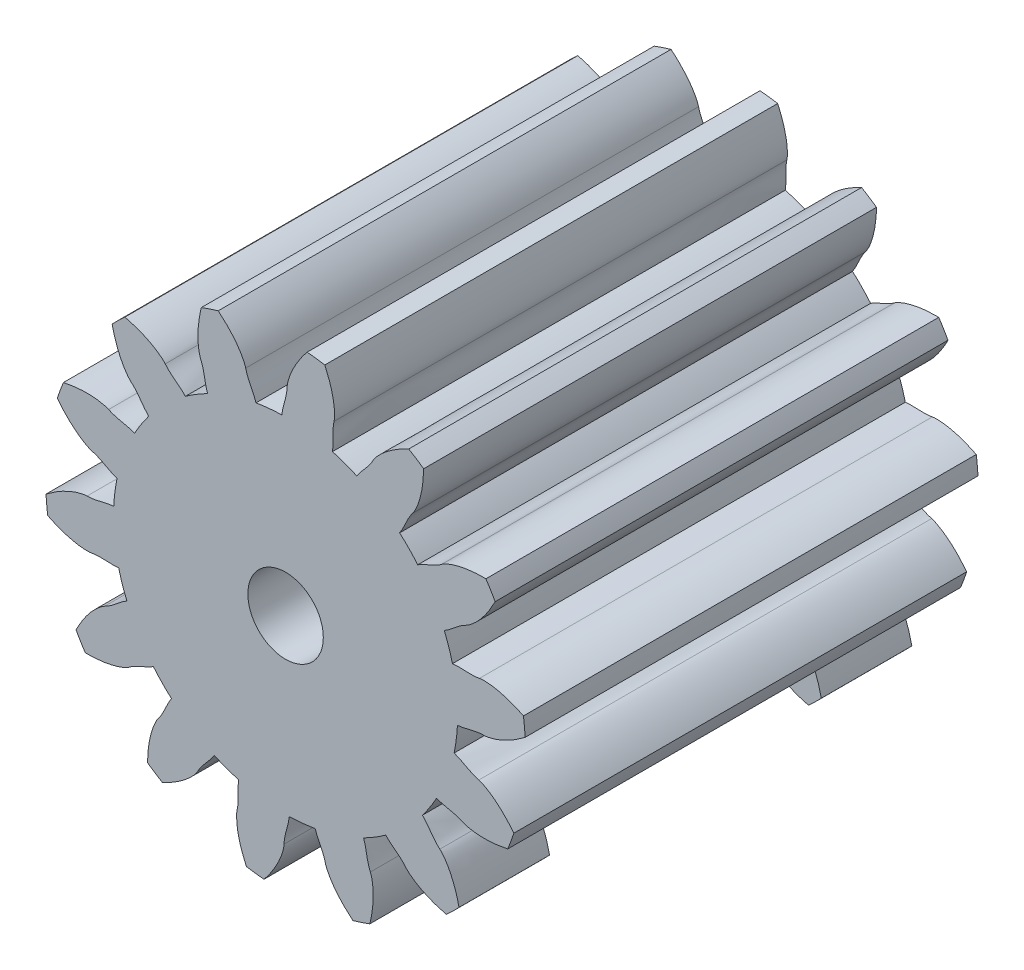
from build123d import *

# Parameters (mm, degrees)
EXTRUDE_1_DEPTH     = 30
SKETCH_4_R          = 2.5
CUT_EXTRUDE_1_DEPTH = 66
CUT_EXTRUDE_START   = -6
CUT_EXTRUDE_2_DEPTH = 18


with BuildPart() as part:
    # 草图3 → 凸台-拉伸1 (new body)
    with BuildSketch(Plane.XY):
        with BuildLine():
            ThreePointArc((-5.16915257, 10.160701832), (-5.920631824, 9.741977151), (-6.638396304, 9.267777215))
            add(Edge.make_bspline(
                [(-6.638396304, 9.267777215), (-6.690388584, 9.321524895), (-6.742285564, 9.375374413), (-6.851473177, 9.477309725), (-6.907912341, 9.526305408), (-7.080462978, 9.66983748), (-7.199376592, 9.760655037), (-7.552933918, 10.037083253), (-7.785800299, 10.227892454), (-7.970905806, 10.463685805)],
                knots=[0, 0, 0, 0, 0.125, 0.125, 0.25, 0.25, 0.5, 0.5, 1, 1, 1, 1], degree=3))
            add(Edge.make_bspline(
                [(-7.970905806, 10.463685805), (-8.010602828, 10.514253148), (-8.056096553, 10.558060329), (-8.148386682, 10.644155499), (-8.196244739, 10.685205378), (-8.343350395, 10.804236571), (-8.446517678, 10.878185133), (-8.764032329, 11.086469421), (-8.985827606, 11.207046594), (-9.67250883, 11.530309395), (-10.152057253, 11.691198834), (-10.643696882, 11.811931116)],
                knots=[0, 0, 0, 0, 0.0625, 0.0625, 0.125, 0.125, 0.25, 0.25, 0.5, 0.5, 1, 1, 1, 1], degree=3))
            ThreePointArc((-10.643696882, 11.811931116), (-11.074186923, 11.409311285), (-11.489458252, 10.991012195))
            add(Edge.make_bspline(
                [(-11.489458252, 10.991012195), (-11.38347984, 10.496213832), (-11.236294102, 10.010267524), (-10.934006793, 9.315376381), (-10.819398101, 9.088979282), (-10.621739867, 8.767211548), (-10.551508259, 8.662694281), (-10.436783614, 8.511828112), (-10.396895617, 8.462380662), (-10.313124681, 8.367024558), (-10.270456441, 8.320097003), (-10.221471948, 8.279225278)],
                knots=[0, 0, 0, 0, 0.5, 0.5, 0.75, 0.75, 0.875, 0.875, 0.9375, 0.9375, 1, 1, 1, 1], degree=3))
            add(Edge.make_bspline(
                [(-10.221471948, 8.279225278), (-9.99128373, 8.08716062), (-9.807518072, 7.848726952), (-9.54175471, 7.487094574), (-9.454526905, 7.365533837), (-9.316196827, 7.188775305), (-9.268899165, 7.130893563), (-9.170260023, 7.018712582), (-9.117982113, 6.96523489), (-9.065808842, 6.911664781)],
                knots=[0, 0, 0, 0, 0.5, 0.5, 0.75, 0.75, 0.875, 0.875, 1, 1, 1, 1], degree=3))
            ThreePointArc((-9.065808842, 6.911664781), (-9.561190424, 6.208352251), (-10.002126234, 5.469686536))
            add(Edge.make_bspline(
                [(-10.002126234, 5.469686536), (-10.072289904, 5.495552917), (-10.142411898, 5.521552401), (-10.285014612, 5.566018213), (-10.357122972, 5.585673763), (-10.574861956, 5.640124775), (-10.721403681, 5.670353884), (-11.159885533, 5.766004326), (-11.452479902, 5.836880539), (-11.721561102, 5.969008738)],
                knots=[0, 0, 0, 0, 0.125, 0.125, 0.25, 0.25, 0.5, 0.5, 1, 1, 1, 1], degree=3))
            add(Edge.make_bspline(
                [(-11.721561102, 5.969008738), (-11.779267231, 5.997344448), (-11.839262885, 6.017074367), (-11.959768712, 6.054600249), (-12.020698207, 6.070820078), (-12.204881522, 6.114236725), (-12.32991711, 6.136099472), (-12.706359092, 6.185992687), (-12.958506206, 6.198395601), (-13.717443083, 6.191705504), (-14.219308595, 6.128593618), (-14.714644369, 6.024055204)],
                knots=[0, 0, 0, 0, 0.0625, 0.0625, 0.125, 0.125, 0.25, 0.25, 0.5, 0.5, 1, 1, 1, 1], degree=3))
            ThreePointArc((-14.714644369, 6.024055204), (-14.927812296, 5.474524642), (-15.120465662, 4.917470708))
            add(Edge.make_bspline(
                [(-15.120465662, 4.917470708), (-14.810297448, 4.517655096), (-14.46684348, 4.1436941), (-13.892990057, 3.648776361), (-13.691501174, 3.494526471), (-13.373807471, 3.290384453), (-13.265182637, 3.226690002), (-13.096360925, 3.140541439), (-13.038968637, 3.113297579), (-12.922120169, 3.063731545), (-12.86331631, 3.039964335), (-12.80144923, 3.024393757)],
                knots=[0, 0, 0, 0, 0.5, 0.5, 0.75, 0.75, 0.875, 0.875, 0.9375, 0.9375, 1, 1, 1, 1], degree=3))
            add(Edge.make_bspline(
                [(-12.80144923, 3.024393757), (-12.51072308, 2.951224405), (-12.241703452, 2.816136024), (-11.845352528, 2.605626911), (-11.714019764, 2.533951197), (-11.512696017, 2.434716434), (-11.444968349, 2.403088473), (-11.30742405, 2.344814822), (-11.23712018, 2.319315621), (-11.166870487, 2.293687755)],
                knots=[0, 0, 0, 0, 0.5, 0.5, 0.75, 0.75, 0.875, 0.875, 1, 1, 1, 1], degree=3))
            ThreePointArc((-11.166870487, 2.293687755), (-11.308038001, 1.445087048), (-11.384812396, 0.588257356))
            add(Edge.make_bspline(
                [(-11.384812396, 0.588257356), (-11.45925068, 0.581119285), (-11.533709167, 0.574119218), (-11.681482765, 0.552308531), (-11.754978377, 0.538730925), (-11.974779831, 0.493316187), (-12.119925282, 0.456969601), (-12.556484951, 0.352897526), (-12.850855405, 0.289802849), (-13.150617466, 0.292096286)],
                knots=[0, 0, 0, 0, 0.125, 0.125, 0.25, 0.25, 0.5, 0.5, 1, 1, 1, 1], degree=3))
            add(Edge.make_bspline(
                [(-13.150617466, 0.292096286), (-13.214903296, 0.292588128), (-13.277518003, 0.284333031), (-13.402371871, 0.265857164), (-13.46430497, 0.254034409), (-13.64908618, 0.21323731), (-13.771225243, 0.178684056), (-14.132035603, 0.060304235), (-14.364593726, -0.037923658), (-15.045469501, -0.373241597), (-15.470251482, -0.647854727), (-15.871176075, -0.956958721)],
                knots=[0, 0, 0, 0, 0.0625, 0.0625, 0.125, 0.125, 0.25, 0.25, 0.5, 0.5, 1, 1, 1, 1], degree=3))
            ThreePointArc((-15.871176075, -0.956958721), (-15.824801366, -1.544558747), (-15.756679407, -2.130036162))
            add(Edge.make_bspline(
                [(-15.756679407, -2.130036162), (-15.30375401, -2.355680637), (-14.832057082, -2.54358876), (-14.100296254, -2.740508566), (-13.851834524, -2.792060165), (-13.477028487, -2.838143636), (-13.351524906, -2.848399804), (-13.162043338, -2.852767982), (-13.098514006, -2.852412271), (-12.971731278, -2.846371074), (-12.908438626, -2.842270553), (-12.845942492, -2.829456039)],
                knots=[0, 0, 0, 0, 0.5, 0.5, 0.75, 0.75, 0.875, 0.875, 0.9375, 0.9375, 1, 1, 1, 1], degree=3))
            add(Edge.make_bspline(
                [(-12.845942492, -2.829456039), (-12.55226029, -2.769237998), (-12.251269328, -2.774225181), (-11.802833004, -2.791917118), (-11.653407346, -2.799511554), (-11.428964567, -2.801567886), (-11.354221189, -2.80067776), (-11.205014068, -2.793502271), (-11.130608781, -2.785972552), (-11.056196481, -2.778582261)],
                knots=[0, 0, 0, 0, 0.5, 0.5, 0.75, 0.75, 0.875, 0.875, 1, 1, 1, 1], degree=3))
            ThreePointArc((-11.056196481, -2.778582261), (-10.815189967, -3.604395369), (-10.512596837, -4.409683407))
            add(Edge.make_bspline(
                [(-10.512596837, -4.409683407), (-10.57656632, -4.448412148), (-10.640613884, -4.487025317), (-10.764289993, -4.570792629), (-10.824616148, -4.61491418), (-11.0029457, -4.751199722), (-11.11794704, -4.846923115), (-11.46611853, -5.130104956), (-11.70396139, -5.314673849), (-11.97503276, -5.442669418)],
                knots=[0, 0, 0, 0, 0.125, 0.125, 0.25, 0.25, 0.5, 0.5, 1, 1, 1, 1], degree=3))
            add(Edge.make_bspline(
                [(-11.97503276, -5.442669418), (-12.033165693, -5.47011886), (-12.085997842, -5.504723948), (-12.190470913, -5.575542193), (-12.241141005, -5.613065891), (-12.389921925, -5.729996369), (-12.484973323, -5.814121929), (-12.758689145, -6.077328211), (-12.925597289, -6.266731672), (-13.393556164, -6.864263623), (-13.657121332, -7.295987498), (-13.884226713, -7.748435235)],
                knots=[0, 0, 0, 0, 0.0625, 0.0625, 0.125, 0.125, 0.25, 0.25, 0.5, 0.5, 1, 1, 1, 1], degree=3))
            ThreePointArc((-13.884226713, -7.748435235), (-13.587494447, -8.257723333), (-13.272089553, -8.755663247))
            add(Edge.make_bspline(
                [(-13.272089553, -8.755663247), (-12.766114402, -8.762444929), (-12.259599876, -8.727082671), (-11.514865849, -8.587002162), (-11.268642166, -8.525645043), (-10.910958725, -8.404542571), (-10.793433922, -8.359329096), (-10.620821647, -8.281051717), (-10.563738034, -8.253166889), (-10.45213192, -8.192714994), (-10.39688636, -8.161558899), (-10.346139299, -8.122897365)],
                knots=[0, 0, 0, 0, 0.5, 0.5, 0.75, 0.75, 0.875, 0.875, 0.9375, 0.9375, 1, 1, 1, 1], degree=3))
            add(Edge.make_bspline(
                [(-10.346139299, -8.122897365), (-10.107668406, -7.941218853), (-9.834321062, -7.815117066), (-9.422617651, -7.63648772), (-9.284694683, -7.578496708), (-9.081586518, -7.482967327), (-9.014631272, -7.449735415), (-8.883313629, -7.37853198), (-8.819543804, -7.339464692), (-8.755707165, -7.300519984)],
                knots=[0, 0, 0, 0, 0.5, 0.5, 0.75, 0.75, 0.875, 0.875, 1, 1, 1, 1], degree=3))
            ThreePointArc((-8.755707165, -7.300519984), (-8.180260921, -7.939983077), (-7.558232546, -8.53423229))
            add(Edge.make_bspline(
                [(-7.558232546, -8.53423229), (-7.599063288, -8.596880999), (-7.640014522, -8.659459459), (-7.715097573, -8.788592251), (-7.750305937, -8.854518933), (-7.85184323, -9.054682256), (-7.913923034, -9.190823264), (-8.104746711, -9.597027235), (-8.238954282, -9.866514212), (-8.427645951, -10.099447694)],
                knots=[0, 0, 0, 0, 0.125, 0.125, 0.25, 0.25, 0.5, 0.5, 1, 1, 1, 1], degree=3))
            add(Edge.make_bspline(
                [(-8.427645951, -10.099447694), (-8.468112047, -10.14940172), (-8.500697584, -10.203502838), (-8.564097683, -10.312637038), (-8.593468936, -10.368429652), (-8.67678168, -10.538333994), (-8.725919318, -10.65536976), (-8.858327827, -11.011271271), (-8.926527786, -11.254336622), (-9.088884767, -11.995734054), (-9.139030809, -12.499060466), (-9.147335971, -13.005239123)],
                knots=[0, 0, 0, 0, 0.0625, 0.0625, 0.125, 0.125, 0.25, 0.25, 0.5, 0.5, 1, 1, 1, 1], degree=3))
            ThreePointArc((-9.147335971, -13.005239123), (-8.659017613, -13.335344539), (-8.158799592, -13.647123844))
            add(Edge.make_bspline(
                [(-8.158799592, -13.647123844), (-7.699989271, -13.433699539), (-7.25897856, -13.182070828), (-6.648775043, -12.732734667), (-6.453557025, -12.57062136), (-6.183839774, -12.306318774), (-6.097570977, -12.21459074), (-5.976015972, -12.069171599), (-5.936684188, -12.019280586), (-5.862359648, -11.916391232), (-5.826103241, -11.864350411), (-5.79715633, -11.807499247)],
                knots=[0, 0, 0, 0, 0.5, 0.5, 0.75, 0.75, 0.875, 0.875, 0.9375, 0.9375, 1, 1, 1, 1], degree=3))
            add(Edge.make_bspline(
                [(-5.79715633, -11.807499247), (-5.661128832, -11.540343921), (-5.469564899, -11.308129169), (-5.176137312, -10.968558275), (-5.077034369, -10.856467645), (-4.93548888, -10.682273317), (-4.889583074, -10.623281606), (-4.802163979, -10.502152937), (-4.761660013, -10.439285838), (-4.721042664, -10.376500188)],
                knots=[0, 0, 0, 0, 0.5, 0.5, 0.75, 0.75, 0.875, 0.875, 1, 1, 1, 1], degree=3))
            ThreePointArc((-4.721042664, -10.376500188), (-3.925130875, -10.702959759), (-3.106867603, -10.968471803))
            add(Edge.make_bspline(
                [(-3.106867603, -10.968471803), (-3.116472575, -11.042632135), (-3.126216586, -11.116781453), (-3.137835458, -11.265703394), (-3.140952583, -11.340377618), (-3.145586912, -11.564773921), (-3.142449513, -11.714368148), (-3.138130407, -12.163140571), (-3.142121234, -12.464170429), (-3.211060503, -12.755906492)],
                knots=[0, 0, 0, 0, 0.125, 0.125, 0.25, 0.25, 0.5, 0.5, 1, 1, 1, 1], degree=3))
            add(Edge.make_bspline(
                [(-3.211060503, -12.755906492), (-3.225844956, -12.818471096), (-3.231729915, -12.881352854), (-3.241499876, -13.007187642), (-3.243754953, -13.070198759), (-3.24509841, -13.259425327), (-3.238589976, -13.386190931), (-3.203466043, -13.764297011), (-3.159449979, -14.012882179), (-2.984048274, -14.751302237), (-2.810843151, -15.226541217), (-2.598703155, -15.686195903)],
                knots=[0, 0, 0, 0, 0.0625, 0.0625, 0.125, 0.125, 0.25, 0.25, 0.5, 0.5, 1, 1, 1, 1], degree=3))
            ThreePointArc((-2.598703155, -15.686195903), (-2.015516145, -15.771737211), (-1.42955931, -15.835604194))
            add(Edge.make_bspline(
                [(-1.42955931, -15.835604194), (-1.10878683, -15.444245201), (-0.820627515, -15.026188191), (-0.465812797, -14.356592914), (-0.360265768, -14.125831948), (-0.231935516, -13.770677617), (-0.194009318, -13.650602885), (-0.147587044, -13.466844027), (-0.13379723, -13.404828356), (-0.11147515, -13.279880042), (-0.101388923, -13.217261817), (-0.099975453, -13.153481094)],
                knots=[0, 0, 0, 0, 0.5, 0.5, 0.75, 0.75, 0.875, 0.875, 0.9375, 0.9375, 1, 1, 1, 1], degree=3))
            add(Edge.make_bspline(
                [(-0.099975453, -13.153481094), (-0.093333264, -12.853762343), (-0.021494329, -12.561427606), (0.095540503, -12.128171343), (0.136194868, -11.984182019), (0.18814286, -11.765824066), (0.203907018, -11.692756589), (0.230113142, -11.545693705), (0.239328942, -11.471478394), (0.248682236, -11.397287271)],
                knots=[0, 0, 0, 0, 0.5, 0.5, 0.75, 0.75, 0.875, 0.875, 1, 1, 1, 1], degree=3))
            ThreePointArc((0.248682236, -11.397287271), (1.107419479, -11.346083998), (1.959850571, -11.230270956))
            add(Edge.make_bspline(
                [(1.959850571, -11.230270956), (1.983373753, -11.301254547), (2.006766885, -11.372288542), (2.060913452, -11.511503814), (2.090504951, -11.580135435), (2.183691471, -11.784320279), (2.251424674, -11.917738753), (2.45003111, -12.320194745), (2.57704746, -12.593144831), (2.641514858, -12.885901569)],
                knots=[0, 0, 0, 0, 0.125, 0.125, 0.25, 0.25, 0.5, 0.5, 1, 1, 1, 1], degree=3))
            add(Edge.make_bspline(
                [(2.641514858, -12.885901569), (2.655340291, -12.948685063), (2.677321498, -13.007892957), (2.723116736, -13.125505211), (2.748424481, -13.183254707), (2.829316399, -13.354324858), (2.890181829, -13.465712817), (3.08588148, -13.79113492), (3.233395645, -13.996004563), (3.711815577, -14.5851941), (4.074066465, -14.938218739), (4.464634691, -15.260309206)],
                knots=[0, 0, 0, 0, 0.0625, 0.0625, 0.125, 0.125, 0.25, 0.25, 0.5, 0.5, 1, 1, 1, 1], degree=3))
            ThreePointArc((4.464634691, -15.260309206), (5.027183014, -15.084343902), (5.582822726, -14.887648922))
            add(Edge.make_bspline(
                [(5.582822726, -14.887648922), (5.70202444, -14.39586869), (5.780258874, -13.894184698), (5.809409386, -13.136951863), (5.804380542, -12.883248277), (5.765906415, -12.507584872), (5.747978266, -12.382945716), (5.710073309, -12.197242836), (5.695589911, -12.13538547), (5.661488367, -12.013125742), (5.643406715, -11.952332421), (5.617006789, -11.894254694)],
                knots=[0, 0, 0, 0, 0.5, 0.5, 0.75, 0.75, 0.875, 0.875, 0.9375, 0.9375, 1, 1, 1, 1], degree=3))
            add(Edge.make_bspline(
                [(5.617006789, -11.894254694), (5.492948102, -11.621335492), (5.430833457, -11.326781249), (5.34829535, -10.885651334), (5.322449041, -10.738282168), (5.274510599, -10.519009061), (5.257010825, -10.446337728), (5.216813533, -10.302468237), (5.192915864, -10.231603966), (5.16915257, -10.160701832)],
                knots=[0, 0, 0, 0, 0.5, 0.5, 0.75, 0.75, 0.875, 0.875, 1, 1, 1, 1], degree=3))
            ThreePointArc((5.16915257, -10.160701832), (5.920631824, -9.741977151), (6.638396304, -9.267777215))
            add(Edge.make_bspline(
                [(6.638396304, -9.267777215), (6.690388584, -9.321524895), (6.742285564, -9.375374413), (6.851473177, -9.477309725), (6.907912341, -9.526305408), (7.080462978, -9.66983748), (7.199376592, -9.760655037), (7.552933918, -10.037083253), (7.785800299, -10.227892454), (7.970905806, -10.463685805)],
                knots=[0, 0, 0, 0, 0.125, 0.125, 0.25, 0.25, 0.5, 0.5, 1, 1, 1, 1], degree=3))
            add(Edge.make_bspline(
                [(7.970905806, -10.463685805), (8.010602828, -10.514253148), (8.056096553, -10.558060329), (8.148386682, -10.644155499), (8.196244739, -10.685205378), (8.343350395, -10.804236571), (8.446517678, -10.878185133), (8.764032329, -11.086469421), (8.985827606, -11.207046594), (9.67250883, -11.530309395), (10.152057253, -11.691198834), (10.643696882, -11.811931116)],
                knots=[0, 0, 0, 0, 0.0625, 0.0625, 0.125, 0.125, 0.25, 0.25, 0.5, 0.5, 1, 1, 1, 1], degree=3))
            ThreePointArc((10.643696882, -11.811931116), (11.074186923, -11.409311285), (11.489458252, -10.991012195))
            add(Edge.make_bspline(
                [(11.489458252, -10.991012195), (11.38347984, -10.496213832), (11.236294102, -10.010267524), (10.934006793, -9.315376381), (10.819398101, -9.088979282), (10.621739867, -8.767211548), (10.551508259, -8.662694281), (10.436783614, -8.511828112), (10.396895617, -8.462380662), (10.313124681, -8.367024558), (10.270456441, -8.320097003), (10.221471948, -8.279225278)],
                knots=[0, 0, 0, 0, 0.5, 0.5, 0.75, 0.75, 0.875, 0.875, 0.9375, 0.9375, 1, 1, 1, 1], degree=3))
            add(Edge.make_bspline(
                [(10.221471948, -8.279225278), (9.99128373, -8.08716062), (9.807518072, -7.848726952), (9.54175471, -7.487094574), (9.454526905, -7.365533837), (9.316196827, -7.188775305), (9.268899165, -7.130893563), (9.170260023, -7.018712582), (9.117982113, -6.96523489), (9.065808842, -6.911664781)],
                knots=[0, 0, 0, 0, 0.5, 0.5, 0.75, 0.75, 0.875, 0.875, 1, 1, 1, 1], degree=3))
            ThreePointArc((9.065808842, -6.911664781), (9.561190424, -6.208352251), (10.002126234, -5.469686536))
            add(Edge.make_bspline(
                [(10.002126234, -5.469686536), (10.072289904, -5.495552917), (10.142411898, -5.521552401), (10.285014612, -5.566018213), (10.357122972, -5.585673763), (10.574861956, -5.640124775), (10.721403681, -5.670353884), (11.159885533, -5.766004326), (11.452479902, -5.836880539), (11.721561102, -5.969008738)],
                knots=[0, 0, 0, 0, 0.125, 0.125, 0.25, 0.25, 0.5, 0.5, 1, 1, 1, 1], degree=3))
            add(Edge.make_bspline(
                [(11.721561102, -5.969008738), (11.779267231, -5.997344448), (11.839262885, -6.017074367), (11.959768712, -6.054600249), (12.020698207, -6.070820078), (12.204881522, -6.114236725), (12.32991711, -6.136099472), (12.706359092, -6.185992687), (12.958506206, -6.198395601), (13.717443083, -6.191705504), (14.219308595, -6.128593618), (14.714644369, -6.024055204)],
                knots=[0, 0, 0, 0, 0.0625, 0.0625, 0.125, 0.125, 0.25, 0.25, 0.5, 0.5, 1, 1, 1, 1], degree=3))
            ThreePointArc((14.714644369, -6.024055204), (14.927812296, -5.474524642), (15.120465662, -4.917470708))
            add(Edge.make_bspline(
                [(15.120465662, -4.917470708), (14.810297448, -4.517655096), (14.46684348, -4.1436941), (13.892990057, -3.648776361), (13.691501174, -3.494526471), (13.373807471, -3.290384453), (13.265182637, -3.226690002), (13.096360925, -3.140541439), (13.038968637, -3.113297579), (12.922120169, -3.063731545), (12.86331631, -3.039964335), (12.80144923, -3.024393757)],
                knots=[0, 0, 0, 0, 0.5, 0.5, 0.75, 0.75, 0.875, 0.875, 0.9375, 0.9375, 1, 1, 1, 1], degree=3))
            add(Edge.make_bspline(
                [(12.80144923, -3.024393757), (12.51072308, -2.951224405), (12.241703452, -2.816136024), (11.845352528, -2.605626911), (11.714019764, -2.533951197), (11.512696017, -2.434716434), (11.444968349, -2.403088473), (11.30742405, -2.344814822), (11.23712018, -2.319315621), (11.166870487, -2.293687755)],
                knots=[0, 0, 0, 0, 0.5, 0.5, 0.75, 0.75, 0.875, 0.875, 1, 1, 1, 1], degree=3))
            ThreePointArc((11.166870487, -2.293687755), (11.308038001, -1.445087048), (11.384812396, -0.588257356))
            add(Edge.make_bspline(
                [(11.384812396, -0.588257356), (11.45925068, -0.581119285), (11.533709167, -0.574119218), (11.681482765, -0.552308531), (11.754978377, -0.538730925), (11.974779831, -0.493316187), (12.119925282, -0.456969601), (12.556484951, -0.352897526), (12.850855405, -0.289802849), (13.150617466, -0.292096286)],
                knots=[0, 0, 0, 0, 0.125, 0.125, 0.25, 0.25, 0.5, 0.5, 1, 1, 1, 1], degree=3))
            add(Edge.make_bspline(
                [(13.150617466, -0.292096286), (13.214903296, -0.292588128), (13.277518003, -0.284333031), (13.402371871, -0.265857164), (13.46430497, -0.254034409), (13.64908618, -0.21323731), (13.771225243, -0.178684056), (14.132035603, -0.060304235), (14.364593726, 0.037923658), (15.045469501, 0.373241597), (15.470251482, 0.647854727), (15.871176075, 0.956958721)],
                knots=[0, 0, 0, 0, 0.0625, 0.0625, 0.125, 0.125, 0.25, 0.25, 0.5, 0.5, 1, 1, 1, 1], degree=3))
            ThreePointArc((15.871176075, 0.956958721), (15.824801366, 1.544558747), (15.756679407, 2.130036162))
            add(Edge.make_bspline(
                [(15.756679407, 2.130036162), (15.30375401, 2.355680637), (14.832057082, 2.54358876), (14.100296254, 2.740508566), (13.851834524, 2.792060165), (13.477028487, 2.838143636), (13.351524906, 2.848399804), (13.162043338, 2.852767982), (13.098514006, 2.852412271), (12.971731278, 2.846371074), (12.908438626, 2.842270553), (12.845942492, 2.829456039)],
                knots=[0, 0, 0, 0, 0.5, 0.5, 0.75, 0.75, 0.875, 0.875, 0.9375, 0.9375, 1, 1, 1, 1], degree=3))
            add(Edge.make_bspline(
                [(12.845942492, 2.829456039), (12.55226029, 2.769237998), (12.251269328, 2.774225181), (11.802833004, 2.791917118), (11.653407346, 2.799511554), (11.428964567, 2.801567886), (11.354221189, 2.80067776), (11.205014068, 2.793502271), (11.130608781, 2.785972552), (11.056196481, 2.778582261)],
                knots=[0, 0, 0, 0, 0.5, 0.5, 0.75, 0.75, 0.875, 0.875, 1, 1, 1, 1], degree=3))
            ThreePointArc((11.056196481, 2.778582261), (10.815189967, 3.604395369), (10.512596837, 4.409683407))
            add(Edge.make_bspline(
                [(10.512596837, 4.409683407), (10.57656632, 4.448412148), (10.640613884, 4.487025317), (10.764289993, 4.570792629), (10.824616148, 4.61491418), (11.0029457, 4.751199722), (11.11794704, 4.846923115), (11.46611853, 5.130104956), (11.70396139, 5.314673849), (11.97503276, 5.442669418)],
                knots=[0, 0, 0, 0, 0.125, 0.125, 0.25, 0.25, 0.5, 0.5, 1, 1, 1, 1], degree=3))
            add(Edge.make_bspline(
                [(11.97503276, 5.442669418), (12.033165693, 5.47011886), (12.085997842, 5.504723948), (12.190470913, 5.575542193), (12.241141005, 5.613065891), (12.389921925, 5.729996369), (12.484973323, 5.814121929), (12.758689145, 6.077328211), (12.925597289, 6.266731672), (13.393556164, 6.864263623), (13.657121332, 7.295987498), (13.884226713, 7.748435235)],
                knots=[0, 0, 0, 0, 0.0625, 0.0625, 0.125, 0.125, 0.25, 0.25, 0.5, 0.5, 1, 1, 1, 1], degree=3))
            ThreePointArc((13.884226713, 7.748435235), (13.587494447, 8.257723333), (13.272089553, 8.755663247))
            add(Edge.make_bspline(
                [(13.272089553, 8.755663247), (12.766114402, 8.762444929), (12.259599876, 8.727082671), (11.514865849, 8.587002162), (11.268642166, 8.525645043), (10.910958725, 8.404542571), (10.793433922, 8.359329096), (10.620821647, 8.281051717), (10.563738034, 8.253166889), (10.45213192, 8.192714994), (10.39688636, 8.161558899), (10.346139299, 8.122897365)],
                knots=[0, 0, 0, 0, 0.5, 0.5, 0.75, 0.75, 0.875, 0.875, 0.9375, 0.9375, 1, 1, 1, 1], degree=3))
            add(Edge.make_bspline(
                [(10.346139299, 8.122897365), (10.107668406, 7.941218853), (9.834321062, 7.815117066), (9.422617651, 7.63648772), (9.284694683, 7.578496708), (9.081586518, 7.482967327), (9.014631272, 7.449735415), (8.883313629, 7.37853198), (8.819543804, 7.339464692), (8.755707165, 7.300519984)],
                knots=[0, 0, 0, 0, 0.5, 0.5, 0.75, 0.75, 0.875, 0.875, 1, 1, 1, 1], degree=3))
            ThreePointArc((8.755707165, 7.300519984), (8.180260921, 7.939983077), (7.558232546, 8.53423229))
            add(Edge.make_bspline(
                [(7.558232546, 8.53423229), (7.599063288, 8.596880999), (7.640014522, 8.659459459), (7.715097573, 8.788592251), (7.750305937, 8.854518933), (7.85184323, 9.054682256), (7.913923034, 9.190823264), (8.104746711, 9.597027235), (8.238954282, 9.866514212), (8.427645951, 10.099447694)],
                knots=[0, 0, 0, 0, 0.125, 0.125, 0.25, 0.25, 0.5, 0.5, 1, 1, 1, 1], degree=3))
            add(Edge.make_bspline(
                [(8.427645951, 10.099447694), (8.468112047, 10.14940172), (8.500697584, 10.203502838), (8.564097683, 10.312637038), (8.593468936, 10.368429652), (8.67678168, 10.538333994), (8.725919318, 10.65536976), (8.858327827, 11.011271271), (8.926527786, 11.254336622), (9.088884767, 11.995734054), (9.139030809, 12.499060466), (9.147335971, 13.005239123)],
                knots=[0, 0, 0, 0, 0.0625, 0.0625, 0.125, 0.125, 0.25, 0.25, 0.5, 0.5, 1, 1, 1, 1], degree=3))
            ThreePointArc((9.147335971, 13.005239123), (8.659017613, 13.335344539), (8.158799592, 13.647123844))
            add(Edge.make_bspline(
                [(8.158799592, 13.647123844), (7.699989271, 13.433699539), (7.25897856, 13.182070828), (6.648775043, 12.732734667), (6.453557025, 12.57062136), (6.183839774, 12.306318774), (6.097570977, 12.21459074), (5.976015972, 12.069171599), (5.936684188, 12.019280586), (5.862359648, 11.916391232), (5.826103241, 11.864350411), (5.79715633, 11.807499247)],
                knots=[0, 0, 0, 0, 0.5, 0.5, 0.75, 0.75, 0.875, 0.875, 0.9375, 0.9375, 1, 1, 1, 1], degree=3))
            add(Edge.make_bspline(
                [(5.79715633, 11.807499247), (5.661128832, 11.540343921), (5.469564899, 11.308129169), (5.176137312, 10.968558275), (5.077034369, 10.856467645), (4.93548888, 10.682273317), (4.889583074, 10.623281606), (4.802163979, 10.502152937), (4.761660013, 10.439285838), (4.721042664, 10.376500188)],
                knots=[0, 0, 0, 0, 0.5, 0.5, 0.75, 0.75, 0.875, 0.875, 1, 1, 1, 1], degree=3))
            ThreePointArc((4.721042664, 10.376500188), (3.925130875, 10.702959759), (3.106867603, 10.968471803))
            add(Edge.make_bspline(
                [(3.106867603, 10.968471803), (3.116472575, 11.042632135), (3.126216586, 11.116781453), (3.137835458, 11.265703394), (3.140952583, 11.340377618), (3.145586912, 11.564773921), (3.142449513, 11.714368148), (3.138130407, 12.163140571), (3.142121234, 12.464170429), (3.211060503, 12.755906492)],
                knots=[0, 0, 0, 0, 0.125, 0.125, 0.25, 0.25, 0.5, 0.5, 1, 1, 1, 1], degree=3))
            add(Edge.make_bspline(
                [(3.211060503, 12.755906492), (3.225844956, 12.818471096), (3.231729915, 12.881352854), (3.241499876, 13.007187642), (3.243754953, 13.070198759), (3.24509841, 13.259425327), (3.238589976, 13.386190931), (3.203466043, 13.764297011), (3.159449979, 14.012882179), (2.984048274, 14.751302237), (2.810843151, 15.226541217), (2.598703155, 15.686195903)],
                knots=[0, 0, 0, 0, 0.0625, 0.0625, 0.125, 0.125, 0.25, 0.25, 0.5, 0.5, 1, 1, 1, 1], degree=3))
            ThreePointArc((2.598703155, 15.686195903), (2.015516145, 15.771737211), (1.42955931, 15.835604194))
            add(Edge.make_bspline(
                [(1.42955931, 15.835604194), (1.10878683, 15.444245201), (0.820627515, 15.026188191), (0.465812797, 14.356592914), (0.360265768, 14.125831948), (0.231935516, 13.770677617), (0.194009318, 13.650602885), (0.147587044, 13.466844027), (0.13379723, 13.404828356), (0.11147515, 13.279880042), (0.101388923, 13.217261817), (0.099975453, 13.153481094)],
                knots=[0, 0, 0, 0, 0.5, 0.5, 0.75, 0.75, 0.875, 0.875, 0.9375, 0.9375, 1, 1, 1, 1], degree=3))
            add(Edge.make_bspline(
                [(0.099975453, 13.153481094), (0.093333264, 12.853762343), (0.021494329, 12.561427606), (-0.095540503, 12.128171343), (-0.136194868, 11.984182019), (-0.18814286, 11.765824066), (-0.203907018, 11.692756589), (-0.230113142, 11.545693705), (-0.239328942, 11.471478394), (-0.248682236, 11.397287271)],
                knots=[0, 0, 0, 0, 0.5, 0.5, 0.75, 0.75, 0.875, 0.875, 1, 1, 1, 1], degree=3))
            ThreePointArc((-0.248682236, 11.397287271), (-1.107419479, 11.346083998), (-1.959850571, 11.230270956))
            add(Edge.make_bspline(
                [(-1.959850571, 11.230270956), (-1.983373753, 11.301254547), (-2.006766885, 11.372288542), (-2.060913452, 11.511503814), (-2.090504951, 11.580135435), (-2.183691471, 11.784320279), (-2.251424674, 11.917738753), (-2.45003111, 12.320194745), (-2.57704746, 12.593144831), (-2.641514858, 12.885901569)],
                knots=[0, 0, 0, 0, 0.125, 0.125, 0.25, 0.25, 0.5, 0.5, 1, 1, 1, 1], degree=3))
            add(Edge.make_bspline(
                [(-2.641514858, 12.885901569), (-2.655340291, 12.948685063), (-2.677321498, 13.007892957), (-2.723116736, 13.125505211), (-2.748424481, 13.183254707), (-2.829316399, 13.354324858), (-2.890181829, 13.465712817), (-3.08588148, 13.79113492), (-3.233395645, 13.996004563), (-3.711815577, 14.5851941), (-4.074066465, 14.938218739), (-4.464634691, 15.260309206)],
                knots=[0, 0, 0, 0, 0.0625, 0.0625, 0.125, 0.125, 0.25, 0.25, 0.5, 0.5, 1, 1, 1, 1], degree=3))
            ThreePointArc((-4.464634691, 15.260309206), (-5.027183014, 15.084343902), (-5.582822726, 14.887648922))
            add(Edge.make_bspline(
                [(-5.582822726, 14.887648922), (-5.70202444, 14.39586869), (-5.780258874, 13.894184698), (-5.809409386, 13.136951863), (-5.804380542, 12.883248277), (-5.765906415, 12.507584872), (-5.747978266, 12.382945716), (-5.710073309, 12.197242836), (-5.695589911, 12.13538547), (-5.661488367, 12.013125742), (-5.643406715, 11.952332421), (-5.617006789, 11.894254694)],
                knots=[0, 0, 0, 0, 0.5, 0.5, 0.75, 0.75, 0.875, 0.875, 0.9375, 0.9375, 1, 1, 1, 1], degree=3))
            add(Edge.make_bspline(
                [(-5.617006789, 11.894254694), (-5.492948102, 11.621335492), (-5.430833457, 11.326781249), (-5.34829535, 10.885651334), (-5.322449041, 10.738282168), (-5.274510599, 10.519009061), (-5.257010825, 10.446337728), (-5.216813533, 10.302468237), (-5.192915864, 10.231603966), (-5.16915257, 10.160701832)],
                knots=[0, 0, 0, 0, 0.5, 0.5, 0.75, 0.75, 0.875, 0.875, 1, 1, 1, 1], degree=3))
        make_face()
    extrude(amount=EXTRUDE_1_DEPTH)

    # 草图4 → 切除-拉伸1 (cut)
    with BuildSketch(Plane.XY.offset(30)):
        Circle(SKETCH_4_R)
    extrude(amount=-CUT_EXTRUDE_1_DEPTH, mode=Mode.SUBTRACT)

    # 草图6 → 切除-拉伸2 (cut)
    with BuildSketch(Plane(origin=(0, 0, 0), x_dir=(-1, 0, 0), z_dir=(0, 0, -1)).offset(CUT_EXTRUDE_START)):
        Polygon((22.930954959, -19.46288681), (20.813353162, -3.055372679), (10.637900586, -4.368646371), (-9.065808842, -6.911664781), (-27.687761378, -9.31506848), (-25.570159581, -25.722582611), align=None)
    extrude(amount=-CUT_EXTRUDE_2_DEPTH, mode=Mode.SUBTRACT)


solid = part.part
